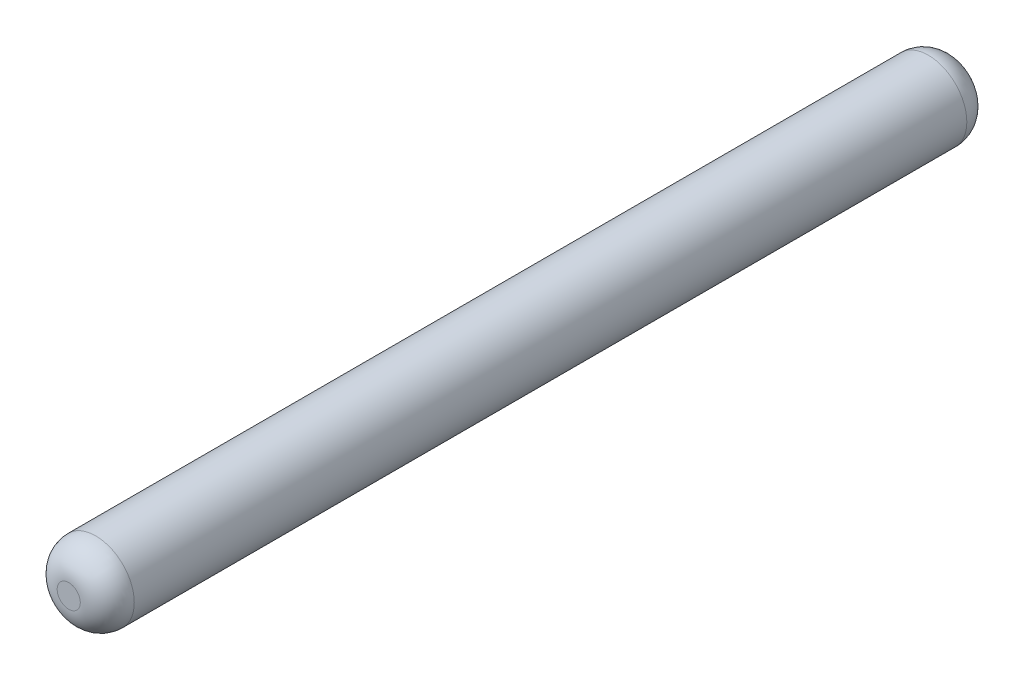
from build123d import *

# Parameters (mm, degrees)
ESQUISSE1_R        = 1
BOSS_EXTRU_1_DEPTH = 23
CONG_1_R           = 0.7


with BuildPart() as part:
    # Esquisse1 → Boss.-Extru.1 (new body)
    with BuildSketch(Plane.XY):
        Circle(ESQUISSE1_R)
    extrude(amount=BOSS_EXTRU_1_DEPTH)

    # Congé1
    cong_1_edges = [part.edges().sort_by_distance(p)[0] for p in [
        (-1, 0, 0),
        (-1, 0, 23),
    ]]
    fillet(cong_1_edges, radius=CONG_1_R)


solid = part.part
